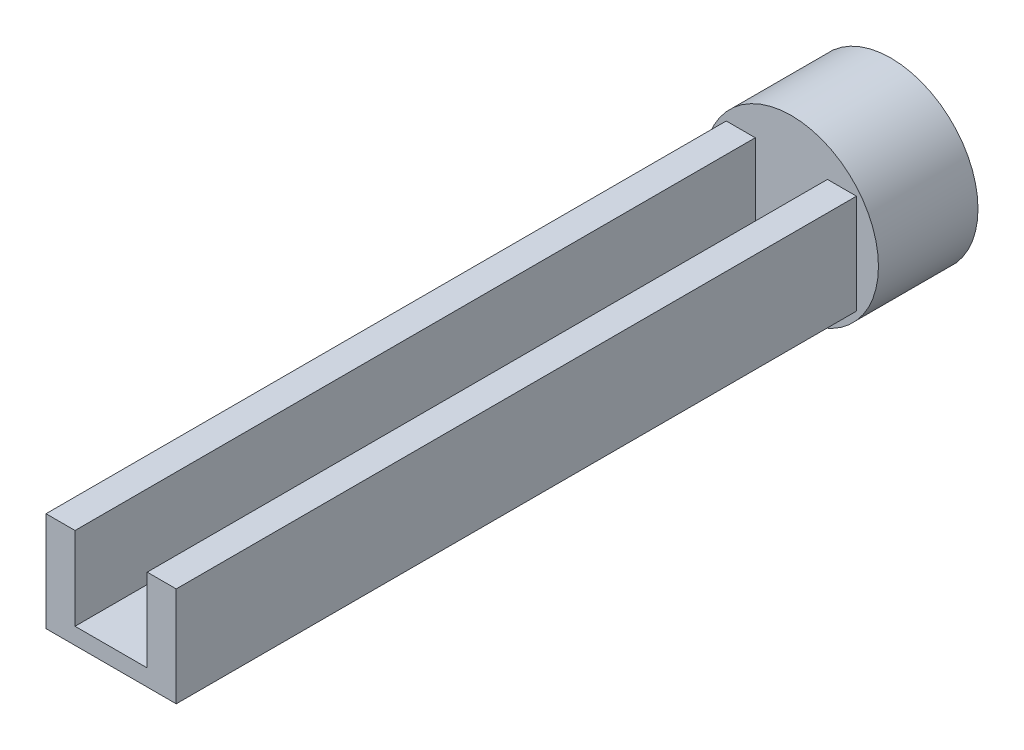
from build123d import *

# Parameters (mm, degrees)
SKETCH2_W           = 15.7
SKETCH2_H           = 82
BOSS_EXTRUDE1_DEPTH = 12
SKETCH3_W           = 8.7
SKETCH3_H           = 82
CUT_EXTRUDE1_DEPTH  = 10
SKETCH4_R           = 10.5
BOSS_EXTRUDE2_DEPTH = 12


with BuildPart() as part:
    # Sketch2 → Boss-Extrude1 (new body)
    with BuildSketch(Plane(origin=(0, 0, 0), x_dir=(1, 0, 0), z_dir=(0, 1, 0))):
        Rectangle(SKETCH2_W, SKETCH2_H)
    extrude(amount=BOSS_EXTRUDE1_DEPTH)

    # Sketch3 → Cut-Extrude1 (cut)
    with BuildSketch(Plane(origin=(0, 12, 0), x_dir=(1, 0, 0), z_dir=(0, 1, 0))):
        Rectangle(SKETCH3_W, SKETCH3_H)
    extrude(amount=-CUT_EXTRUDE1_DEPTH, mode=Mode.SUBTRACT)

    # Sketch4 → Boss-Extrude2 (add)
    with BuildSketch(Plane(origin=(0, 0, -41), x_dir=(-1, 0, 0), z_dir=(0, 0, -1))):
        with Locations((0, 6)):
            Circle(SKETCH4_R)
    extrude(amount=BOSS_EXTRUDE2_DEPTH)


solid = part.part
